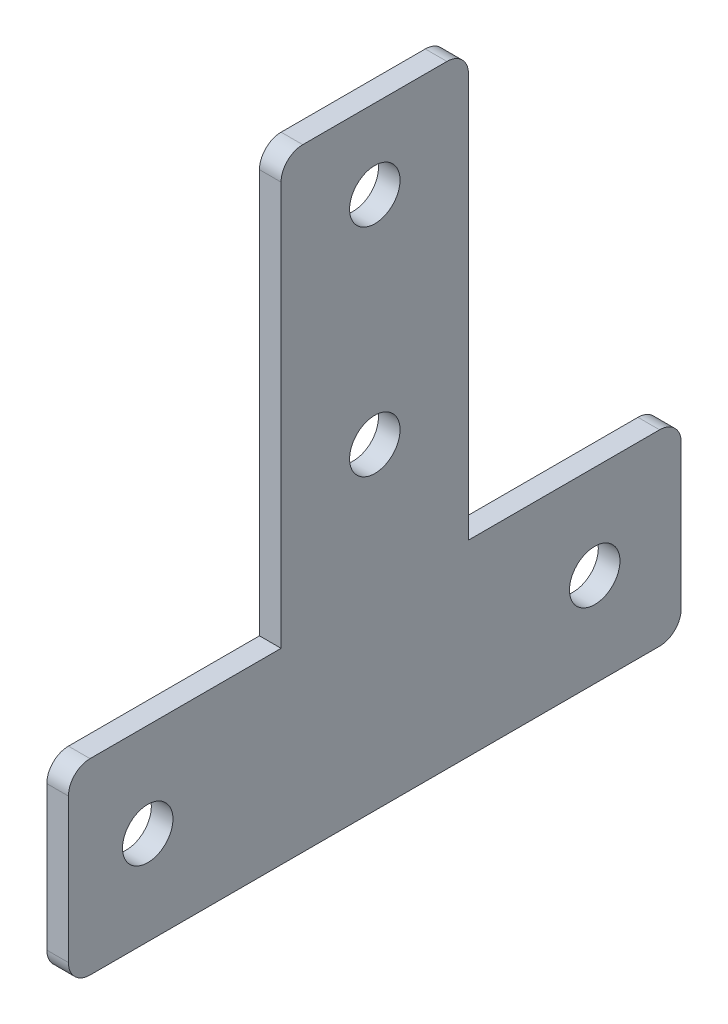
from build123d import *

# Parameters (mm, degrees)
SKETCH1_W           = 85
SKETCH1_H           = 85
BOSS_EXTRUDE1_DEPTH = 3
SKETCH5_W           = 29.5
SKETCH5_H           = 59
CUT_EXTRUDE2_DEPTH  = 121.245582039
DIAMETERHOLE2_D     = 7
FILLET2_R           = 3


with BuildPart() as part:
    # Sketch1 → Boss-Extrude1 (new body)
    with BuildSketch(Plane(origin=(0, 0, 0), x_dir=(0, 0, -1), z_dir=(1, 0, 0))):
        with Locations((42.5, 42.5)):
            Rectangle(SKETCH1_W, SKETCH1_H)
    extrude(amount=BOSS_EXTRUDE1_DEPTH)

    # Sketch5 → Cut-Extrude2 (cut, through all)
    with BuildSketch(Plane(origin=(0, 0, 0), x_dir=(0, 0, -1), z_dir=(1, 0, 0))):
        with Locations((14.75, 55.5)):
            Rectangle(SKETCH5_W, SKETCH5_H)
        with Locations((70.25, 55.5)):
            Rectangle(SKETCH5_W, SKETCH5_H)
    extrude(amount=CUT_EXTRUDE2_DEPTH, mode=Mode.SUBTRACT)

    # DiameterHole2 (through all)
    with Locations(Plane(origin=(3, 0, 0), x_dir=(0, 0, -1), z_dir=(1, 0, 0))):
        with Locations((42.5, 74), (42.5, 44), (11, 13), (73, 13)):
            Hole(DIAMETERHOLE2_D / 2)

    # Fillet2
    fillet2_edges = [part.edges().sort_by_distance(p)[0] for p in [
        (1.5, 0, -85),
        (1.5, 0, 0),
        (1.5, 26, -85),
        (1.5, 26, 0),
        (1.5, 85, -55.5),
        (1.5, 85, -29.5),
    ]]
    fillet(fillet2_edges, radius=FILLET2_R)


solid = part.part
